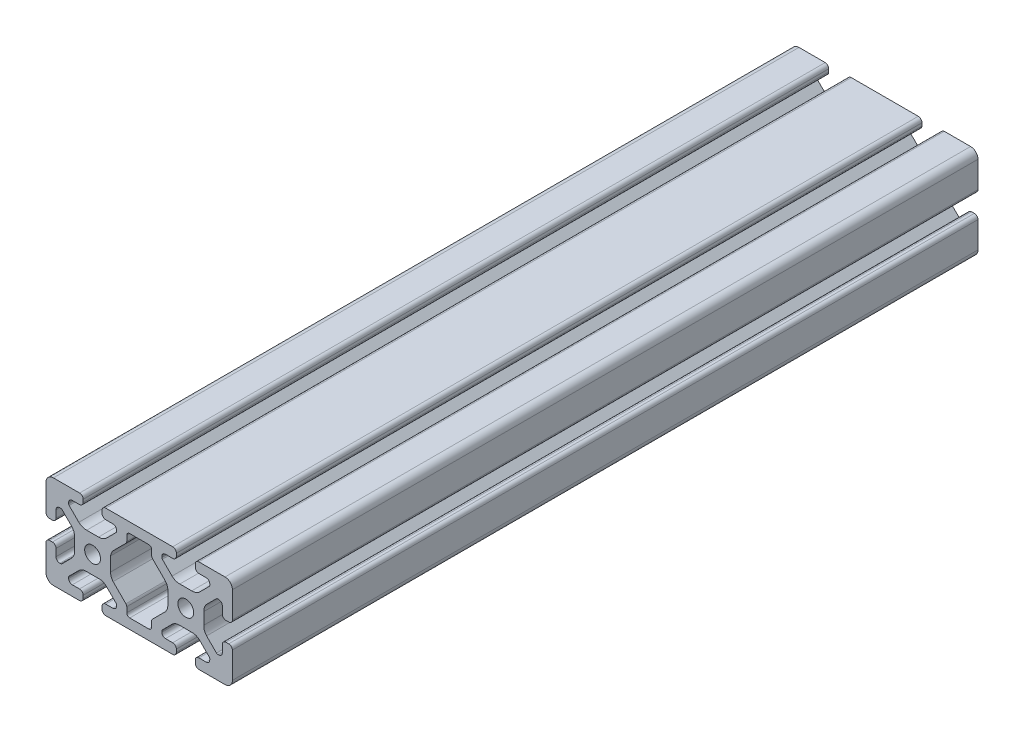
from build123d import *

# Parameters (mm, degrees)
SKETCH1_R           = 3.4
BOSS_EXTRUDE1_DEPTH = 320


with BuildPart() as part:
    # Sketch1 → Boss-Extrude1 (new body)
    with BuildSketch(Plane.XY):
        with BuildLine():
            Line((-14.371895096, 20), (14.371895096, 20))
            ThreePointArc((14.371895096, 20), (15.50899084, 19.51254943), (15.94, 18.352883145))
            Line((15.94, 18.352883145), (15.94, 17.172883145))
            ThreePointArc((15.94, 17.172883145), (15.453758432, 16.112250378), (14.37, 15.68))
            Line((14.37, 15.68), (11.285, 15.68))
            ThreePointArc((11.285, 15.68), (10.174842354, 15.220157646), (9.715, 14.11))
            Line((9.715, 14.11), (9.715, 13.654503602))
            ThreePointArc((9.715, 13.654503602), (9.772851555, 13.363664194), (9.937598846, 13.117102448))
            Line((9.937598846, 13.117102448), (14.091872782, 8.962828513))
            ThreePointArc((14.091872782, 8.962828513), (15.647416634, 8.002049766), (17.450629992, 7.7))
            Line((17.450629992, 7.7), (22.549370008, 7.7))
            ThreePointArc((22.549370008, 7.7), (24.352583366, 8.002049766), (25.908127218, 8.962828513))
            Line((25.908127218, 8.962828513), (30.062401154, 13.117102448))
            ThreePointArc((30.062401154, 13.117102448), (30.227148445, 13.363664194), (30.285, 13.654503602))
            Line((30.285, 13.654503602), (30.285, 14.11))
            ThreePointArc((30.285, 14.11), (29.825157646, 15.220157646), (28.715, 15.68))
            Line((28.715, 15.68), (25.63, 15.68))
            ThreePointArc((25.63, 15.68), (24.519842354, 16.139842354), (24.06, 17.25))
            Line((24.06, 17.25), (24.06, 18.431164164))
            ThreePointArc((24.06, 18.431164164), (24.498672143, 19.519739968), (25.569550674, 20))
            Line((25.569550674, 20), (33, 20))
            Line((33, 20), (36.83, 20))
            ThreePointArc((36.83, 20), (39.067780363, 19.075288119), (40, 16.840624931))
            Line((40, 16.840624931), (40, 13.010624931))
            Line((40, 13.010624931), (40, 5.582508737))
            ThreePointArc((40, 5.582508737), (39.486387554, 4.464397964), (38.324306777, 4.06))
            Line((38.324306777, 4.06), (37.144306789, 4.06))
            ThreePointArc((37.144306789, 4.06), (36.103082753, 4.554299861), (35.68, 5.626438298))
            Line((35.68, 5.626438298), (35.68, 8.711438298))
            ThreePointArc((35.68, 8.711438298), (35.220157646, 9.821595945), (34.11, 10.281438298))
            Line((34.11, 10.281438298), (33.650941901, 10.281438298))
            ThreePointArc((33.650941901, 10.281438298), (33.360102492, 10.223586743), (33.113540747, 10.058839452))
            Line((33.113540747, 10.058839452), (29.01112516, 5.956423865))
            ThreePointArc((29.01112516, 5.956423865), (28.027864944, 4.392105869), (27.715866667, 2.570966522))
            Line((27.715866667, 2.570966522), (27.715866667, -2.502014759))
            ThreePointArc((27.715866667, -2.502014759), (27.988460835, -4.298258683), (28.915473265, -5.86077197))
            Line((28.915473265, -5.86077197), (33.171894658, -10.117193363))
            ThreePointArc((33.171894658, -10.117193363), (33.418456403, -10.281940654), (33.709295811, -10.339792209))
            Line((33.709295811, -10.339792209), (34.110956402, -10.339792209))
            ThreePointArc((34.110956402, -10.339792209), (35.240319888, -9.860405851), (35.68, -8.714999999))
            Line((35.68, -8.714999999), (35.68, -5.629999999))
            ThreePointArc((35.68, -5.629999999), (36.139842353, -4.519842353), (37.249999999, -4.06))
            Line((37.249999999, -4.06), (38.431164149, -4.06))
            ThreePointArc((38.431164149, -4.06), (39.519739962, -4.498672137), (40, -5.569550674))
            Line((40, -5.569550674), (40, -13))
            Line((40, -13), (40, -16.83))
            ThreePointArc((40, -16.83), (39.153330856, -18.99480488), (37.057427332, -20))
            Line((37.057427332, -20), (33.227427332, -20))
            Line((33.227427332, -20), (25.796978006, -20))
            ThreePointArc((25.796978006, -20), (24.580537154, -19.606606664), (24.06, -18.438904761))
            Line((24.06, -18.438904761), (24.06, -17.25))
            ThreePointArc((24.06, -17.25), (24.519842354, -16.139842354), (25.63, -15.68))
            Line((25.63, -15.68), (28.715, -15.68))
            ThreePointArc((28.715, -15.68), (29.825157646, -15.220157646), (30.285, -14.11))
            Line((30.285, -14.11), (30.285, -13.654503602))
            ThreePointArc((30.285, -13.654503602), (30.227148445, -13.363664194), (30.062401154, -13.117102448))
            Line((30.062401154, -13.117102448), (26.309520343, -9.364221638))
            ThreePointArc((26.309520343, -9.364221638), (24.979669869, -8.257223741), (23.341546451, -7.7))
            Line((23.341546451, -7.7), (16.658453549, -7.7))
            ThreePointArc((16.658453549, -7.7), (15.020330131, -8.257223741), (13.690479657, -9.364221638))
            Line((13.690479657, -9.364221638), (9.937598846, -13.117102448))
            ThreePointArc((9.937598846, -13.117102448), (9.772851555, -13.363664194), (9.715, -13.654503602))
            Line((9.715, -13.654503602), (9.715, -14.11))
            ThreePointArc((9.715, -14.11), (10.174842354, -15.220157646), (11.285, -15.68))
            Line((11.285, -15.68), (14.37, -15.68))
            ThreePointArc((14.37, -15.68), (15.480157646, -16.139842354), (15.94, -17.25))
            Line((15.94, -17.25), (15.94, -18.43))
            ThreePointArc((15.94, -18.43), (15.480157646, -19.540157646), (14.37, -20))
            Line((14.37, -20), (5.99100603, -20))
            Line((5.99100603, -20), (-1.780052417, -20))
            Line((-1.780052417, -20), (-5.99100603, -20))
            Line((-5.99100603, -20), (-14.37, -20))
            ThreePointArc((-14.37, -20), (-15.480157646, -19.540157646), (-15.94, -18.43))
            Line((-15.94, -18.43), (-15.94, -17.25))
            ThreePointArc((-15.94, -17.25), (-15.480157646, -16.139842354), (-14.37, -15.68))
            Line((-14.37, -15.68), (-11.285, -15.68))
            ThreePointArc((-11.285, -15.68), (-10.174842354, -15.220157646), (-9.715, -14.11))
            Line((-9.715, -14.11), (-9.715, -13.654503602))
            ThreePointArc((-9.715, -13.654503602), (-9.772851555, -13.363664194), (-9.937598846, -13.117102448))
            Line((-9.937598846, -13.117102448), (-13.690479657, -9.364221638))
            ThreePointArc((-13.690479657, -9.364221638), (-15.020330131, -8.257223741), (-16.658453549, -7.7))
            Line((-16.658453549, -7.7), (-23.341546451, -7.7))
            ThreePointArc((-23.341546451, -7.7), (-24.979669869, -8.257223741), (-26.309520343, -9.364221638))
            Line((-26.309520343, -9.364221638), (-30.062401154, -13.117102448))
            ThreePointArc((-30.062401154, -13.117102448), (-30.227148445, -13.363664194), (-30.285, -13.654503602))
            Line((-30.285, -13.654503602), (-30.285, -14.11))
            ThreePointArc((-30.285, -14.11), (-29.825157646, -15.220157646), (-28.715, -15.68))
            Line((-28.715, -15.68), (-25.63, -15.68))
            ThreePointArc((-25.63, -15.68), (-24.519842354, -16.139842354), (-24.06, -17.25))
            Line((-24.06, -17.25), (-24.06, -18.438904761))
            ThreePointArc((-24.06, -18.438904761), (-24.580537154, -19.606606664), (-25.796978006, -20))
            Line((-25.796978006, -20), (-33.227427332, -20))
            Line((-33.227427332, -20), (-37.057427332, -20))
            ThreePointArc((-37.057427332, -20), (-39.153330856, -18.99480488), (-40, -16.83))
            Line((-40, -16.83), (-40, -13))
            Line((-40, -13), (-40, -5.569550674))
            ThreePointArc((-40, -5.569550674), (-39.519320595, -4.498268351), (-38.43, -4.06))
            Line((-38.43, -4.06), (-37.249999999, -4.06))
            ThreePointArc((-37.249999999, -4.06), (-36.139842353, -4.519842353), (-35.68, -5.629999999))
            Line((-35.68, -5.629999999), (-35.68, -8.714999999))
            ThreePointArc((-35.68, -8.714999999), (-35.240319888, -9.860405851), (-34.110956402, -10.339792209))
            Line((-34.110956402, -10.339792209), (-33.709295811, -10.339792209))
            ThreePointArc((-33.709295811, -10.339792209), (-33.418456403, -10.281940654), (-33.171894658, -10.117193363))
            Line((-33.171894658, -10.117193363), (-28.915473265, -5.86077197))
            ThreePointArc((-28.915473265, -5.86077197), (-27.988460835, -4.298258683), (-27.715866667, -2.502014759))
            Line((-27.715866667, -2.502014759), (-27.715866667, 2.570966522))
            ThreePointArc((-27.715866667, 2.570966522), (-28.027864944, 4.392105869), (-29.01112516, 5.956423865))
            Line((-29.01112516, 5.956423865), (-33.113540747, 10.058839452))
            ThreePointArc((-33.113540747, 10.058839452), (-33.360102492, 10.223586743), (-33.650941901, 10.281438298))
            Line((-33.650941901, 10.281438298), (-34.11, 10.281438298))
            ThreePointArc((-34.11, 10.281438298), (-35.220157646, 9.821595945), (-35.68, 8.711438298))
            Line((-35.68, 8.711438298), (-35.68, 5.626438298))
            ThreePointArc((-35.68, 5.626438298), (-36.103082753, 4.554299861), (-37.144306789, 4.06))
            Line((-37.144306789, 4.06), (-38.324306777, 4.06))
            ThreePointArc((-38.324306777, 4.06), (-39.486387554, 4.464397964), (-40, 5.582508737))
            Line((-40, 5.582508737), (-40, 13.010624931))
            Line((-40, 13.010624931), (-40, 16.840624931))
            ThreePointArc((-40, 16.840624931), (-39.067780363, 19.075288119), (-36.83, 20))
            Line((-36.83, 20), (-33, 20))
            Line((-33, 20), (-25.569550674, 20))
            ThreePointArc((-25.569550674, 20), (-24.498672143, 19.519739968), (-24.06, 18.431164164))
            Line((-24.06, 18.431164164), (-24.06, 17.25))
            ThreePointArc((-24.06, 17.25), (-24.519842354, 16.139842354), (-25.63, 15.68))
            Line((-25.63, 15.68), (-28.715, 15.68))
            ThreePointArc((-28.715, 15.68), (-29.825157646, 15.220157646), (-30.285, 14.11))
            Line((-30.285, 14.11), (-30.285, 13.654503602))
            ThreePointArc((-30.285, 13.654503602), (-30.227148445, 13.363664194), (-30.062401154, 13.117102448))
            Line((-30.062401154, 13.117102448), (-25.908127218, 8.962828513))
            ThreePointArc((-25.908127218, 8.962828513), (-24.352583366, 8.002049766), (-22.549370008, 7.7))
            Line((-22.549370008, 7.7), (-17.450629992, 7.7))
            ThreePointArc((-17.450629992, 7.7), (-15.647416634, 8.002049766), (-14.091872782, 8.962828513))
            Line((-14.091872782, 8.962828513), (-9.937598846, 13.117102448))
            ThreePointArc((-9.937598846, 13.117102448), (-9.772851555, 13.363664194), (-9.715, 13.654503602))
            Line((-9.715, 13.654503602), (-9.715, 14.11))
            ThreePointArc((-9.715, 14.11), (-10.174842354, 15.220157646), (-11.285, 15.68))
            Line((-11.285, 15.68), (-14.37, 15.68))
            ThreePointArc((-14.37, 15.68), (-15.453758432, 16.112250378), (-15.94, 17.172883145))
            Line((-15.94, 17.172883145), (-15.94, 18.352883145))
            ThreePointArc((-15.94, 18.352883145), (-15.50899084, 19.51254943), (-14.371895096, 20))
        make_face()
        with Locations((-20, 0)):
            Circle(SKETCH1_R, mode=Mode.SUBTRACT)
        with Locations((20, 0)):
            Circle(SKETCH1_R, mode=Mode.SUBTRACT)
        with BuildLine():
            Line((4.071751167, 15.68), (-4.071751167, 15.68))
            ThreePointArc((-4.071751167, 15.68), (-4.969776779, 15.308025612), (-5.341751167, 14.41))
            Line((-5.341751167, 14.41), (-5.341751167, 12.129598762))
            ThreePointArc((-5.341751167, 12.129598762), (-5.438424161, 11.643590803), (-5.713725555, 11.23157315))
            Line((-5.713725555, 11.23157315), (-10.598777023, 6.346521682))
            ThreePointArc((-10.598777023, 6.346521682), (-11.737774423, 4.964558417), (-12.284133333, 3.259087959))
            Line((-12.284133333, 3.259087959), (-12.284133333, -2.724972544))
            ThreePointArc((-12.284133333, -2.724972544), (-12.005210609, -4.328708179), (-11.201199443, -5.744099262))
            Line((-11.201199443, -5.744099262), (-5.713725555, -11.23157315))
            ThreePointArc((-5.713725555, -11.23157315), (-5.438424161, -11.643590803), (-5.341751167, -12.129598762))
            Line((-5.341751167, -12.129598762), (-5.341751167, -14.41))
            ThreePointArc((-5.341751167, -14.41), (-4.969776779, -15.308025612), (-4.071751167, -15.68))
            Line((-4.071751167, -15.68), (4.071751167, -15.68))
            ThreePointArc((4.071751167, -15.68), (4.969776779, -15.308025612), (5.341751167, -14.41))
            Line((5.341751167, -14.41), (5.341751167, -12.129598762))
            ThreePointArc((5.341751167, -12.129598762), (5.438424161, -11.643590803), (5.713725555, -11.23157315))
            Line((5.713725555, -11.23157315), (11.201199443, -5.744099262))
            ThreePointArc((11.201199443, -5.744099262), (12.005210609, -4.328708179), (12.284133333, -2.724972544))
            Line((12.284133333, -2.724972544), (12.284133333, 3.259087959))
            ThreePointArc((12.284133333, 3.259087959), (11.737774423, 4.964558417), (10.598777023, 6.346521682))
            Line((10.598777023, 6.346521682), (5.713725555, 11.23157315))
            ThreePointArc((5.713725555, 11.23157315), (5.438424161, 11.643590803), (5.341751167, 12.129598762))
            Line((5.341751167, 12.129598762), (5.341751167, 14.41))
            ThreePointArc((5.341751167, 14.41), (4.969776779, 15.308025612), (4.071751167, 15.68))
        make_face(mode=Mode.SUBTRACT)
    extrude(amount=BOSS_EXTRUDE1_DEPTH)


solid = part.part
